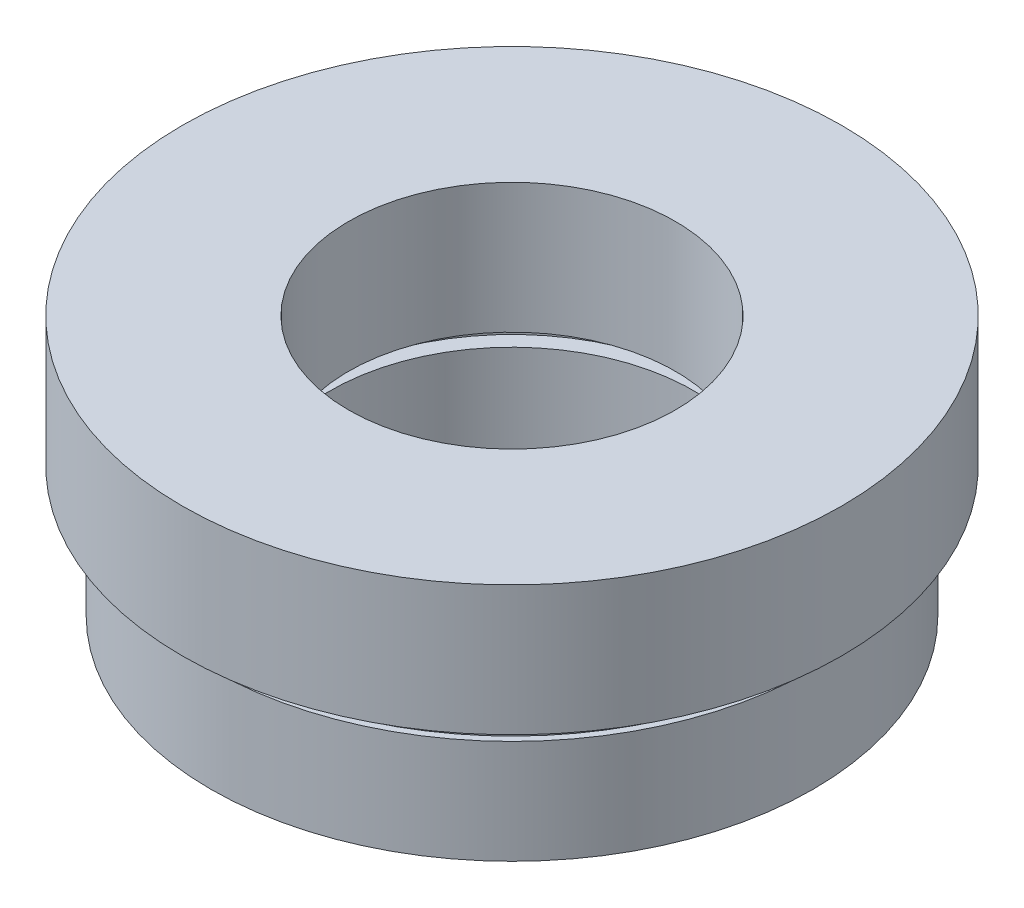
from build123d import *


with BuildPart() as part:
    # 草图1 → 旋转1 (revolve)
    with BuildSketch(Plane.XY, mode=Mode.PRIVATE) as revolve_1_sk:
        Polygon((11.6, 0), (7, 0), (7, 4), (7.6, 4), (7.6, 5), (6.295, 5), (6.295, 10), (12.7, 10), (12.7, 5), (11.35, 5), (11.35, 4), (11.6, 4), align=None)
    revolve(revolve_1_sk.sketch.rotate(Axis((0, 13.744680851, 0), (0, -1, 0)), 90), axis=Axis((0, 13.744680851, 0), (0, -1, 0)))  # turned: the seam where the file's is


solid = part.part
